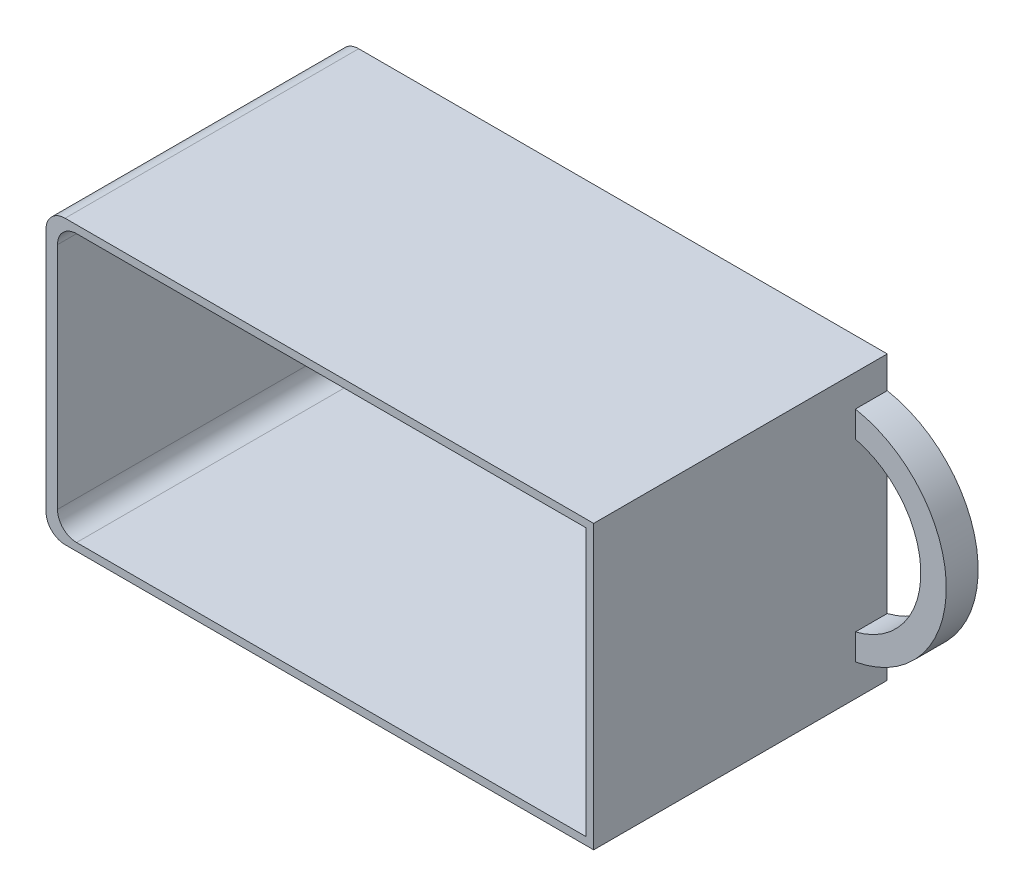
from build123d import *

# Parameters (mm, degrees)
SKETCH_1_W          = 86
SKETCH_1_H          = 44.4
EXTRUDE_1_DEPTH     = 46.1
EXTRUDE_2_DEPTH     = 5
SKETCH_3_W          = 83
SKETCH_3_H          = 42
CUT_EXTRUDE_1_DEPTH = 44.9
FILLET_1_R          = 3


with BuildPart() as part:
    # Эскиз1 → Бобышка-Вытянуть1 (new body)
    with BuildSketch(Plane.XY):
        Rectangle(SKETCH_1_W, SKETCH_1_H)
    extrude(amount=EXTRUDE_1_DEPTH)

    # Эскиз2 → Бобышка-Вытянуть2 (add)
    with BuildSketch(Plane.XY):
        with BuildLine():
            Line((43, 13.108775687), (43, 17.2))
            ThreePointArc((43, 17.2), (57.273546839, 0), (43, -17.2))
            Line((43, -17.2), (43, -13.108775687))
            ThreePointArc((43, -13.108775687), (53.273546839, 0), (43, 13.108775687))
        make_face()
    extrude(amount=EXTRUDE_2_DEPTH)

    # Эскиз3 → Вырез-Вытянуть1 (cut)
    with BuildSketch(Plane.XY.offset(46.1)):
        with Locations((0.3, 0)):
            Rectangle(SKETCH_3_W, SKETCH_3_H)
    extrude(amount=-CUT_EXTRUDE_1_DEPTH, mode=Mode.SUBTRACT)

    # Скругление1
    fillet_1_edges = [part.edges().sort_by_distance(p)[0] for p in [
        (-41.2, 21, 23.65),
        (-41.2, -21, 23.65),
        (-43, -22.2, 23.05),
        (-43, 22.2, 23.05),
    ]]
    fillet(fillet_1_edges, radius=FILLET_1_R)


solid = part.part
